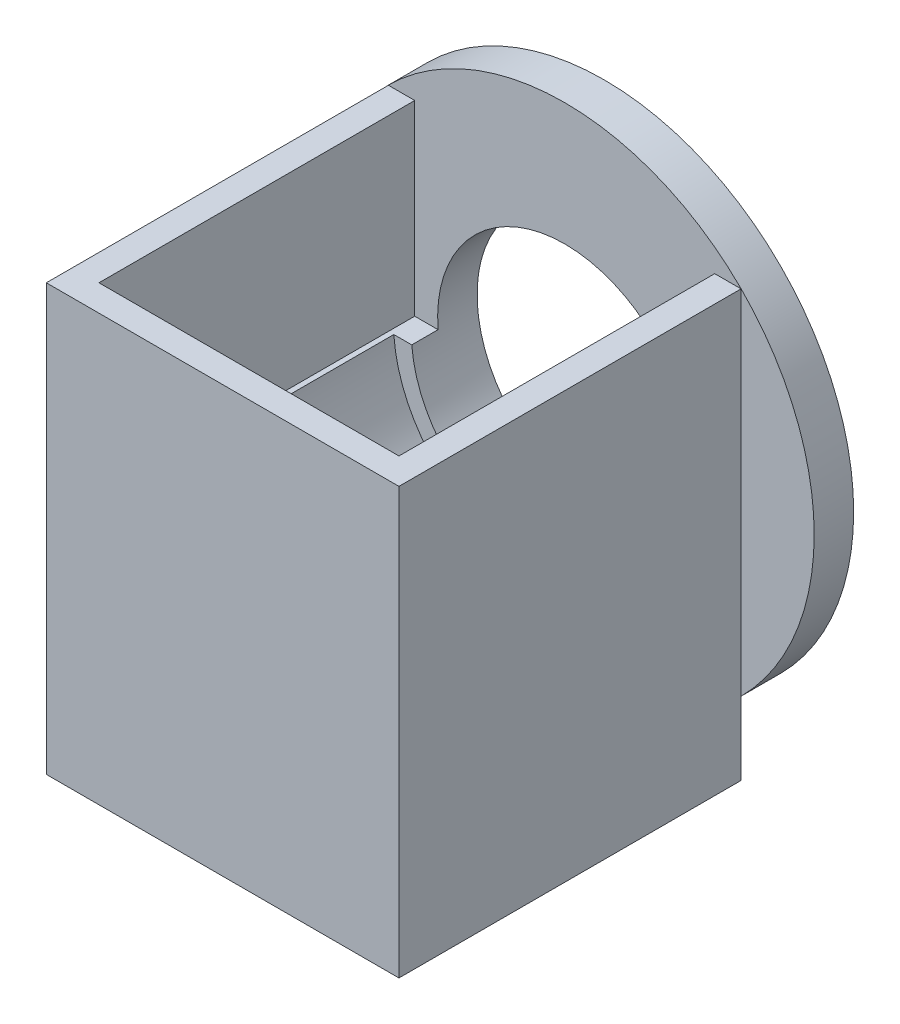
from build123d import *

# Parameters (mm, degrees)
SKETCH3_R           = 47.4
BOSS_EXTRUDE2_DEPTH = 7.5
SKETCH4_R           = 24.15
CUT_EXTRUDE1_DEPTH  = 15
BOSS_EXTRUDE4_DEPTH = 65
SKETCH6_R           = 24.15
CUT_EXTRUDE2_DEPTH  = 5
SKETCH7_W           = 57
SKETCH7_H           = 60
CUT_EXTRUDE3_DEPTH  = 35.5
SKETCH8_R           = 27.55
CUT_EXTRUDE4_DEPTH  = 55


with BuildPart() as part:
    # Sketch3 → Boss-Extrude2 (new body)
    with BuildSketch(Plane.XY):
        Circle(SKETCH3_R)
    extrude(amount=BOSS_EXTRUDE2_DEPTH)

    # Sketch4 → Cut-Extrude1 (cut)
    with BuildSketch(Plane.XY.offset(7.5)):
        Circle(SKETCH4_R)
    extrude(amount=-CUT_EXTRUDE1_DEPTH, mode=Mode.SUBTRACT)

    # Sketch5 → Boss-Extrude4 (add)
    with BuildSketch(Plane.XY.offset(7.5)):
        Polygon((-33.5, -47.4), (33.5, -47.4), (33.5, -33.5), (33.5, 33.5), (0, 33.5), (-33.5, 33.5), (-33.5, -33.5), align=None)
    extrude(amount=BOSS_EXTRUDE4_DEPTH)

    # Sketch6 → Cut-Extrude2 (cut)
    with BuildSketch(Plane(origin=(0, 0, 7.5), x_dir=(-1, 0, 0), z_dir=(0, 0, -1))):
        Circle(SKETCH6_R)
    extrude(amount=-CUT_EXTRUDE2_DEPTH, mode=Mode.SUBTRACT)

    # Sketch7 → Cut-Extrude3 (cut)
    with BuildSketch(Plane(origin=(0, 33.5, 0), x_dir=(1, 0, 0), z_dir=(0, 1, 0))):
        with Locations((0, -37.5)):
            Rectangle(SKETCH7_W, SKETCH7_H)
    extrude(amount=-CUT_EXTRUDE3_DEPTH, mode=Mode.SUBTRACT)

    # Sketch8 → Cut-Extrude4 (cut)
    with BuildSketch(Plane(origin=(0, 0, 12.5), x_dir=(-1, 0, 0), z_dir=(0, 0, -1))):
        Circle(SKETCH8_R)
    extrude(amount=-CUT_EXTRUDE4_DEPTH, mode=Mode.SUBTRACT)


solid = part.part
